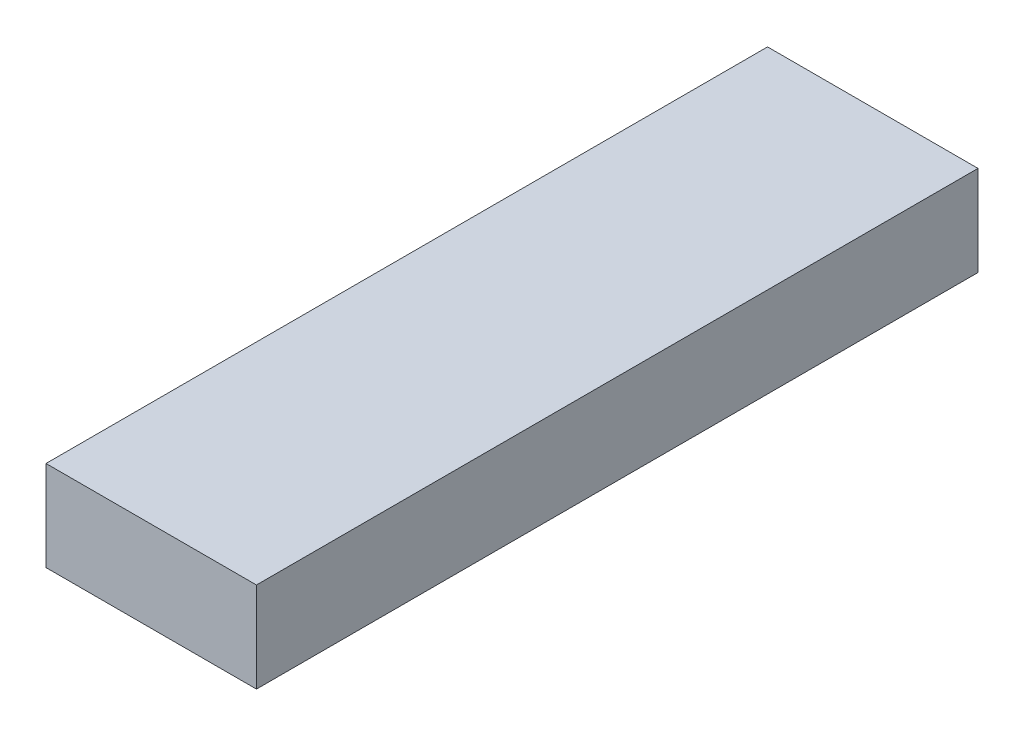
from build123d import *

# Parameters (mm, degrees)
SKETCH1_W           = 88.9
SKETCH1_H           = 38.1
BOSS_EXTRUDE1_DEPTH = 304.8


with BuildPart() as part:
    # Sketch1 → Boss-Extrude1 (new body)
    with BuildSketch(Plane.XY):
        with Locations((44.45, 19.05)):
            Rectangle(SKETCH1_W, SKETCH1_H)
    extrude(amount=BOSS_EXTRUDE1_DEPTH)


solid = part.part
